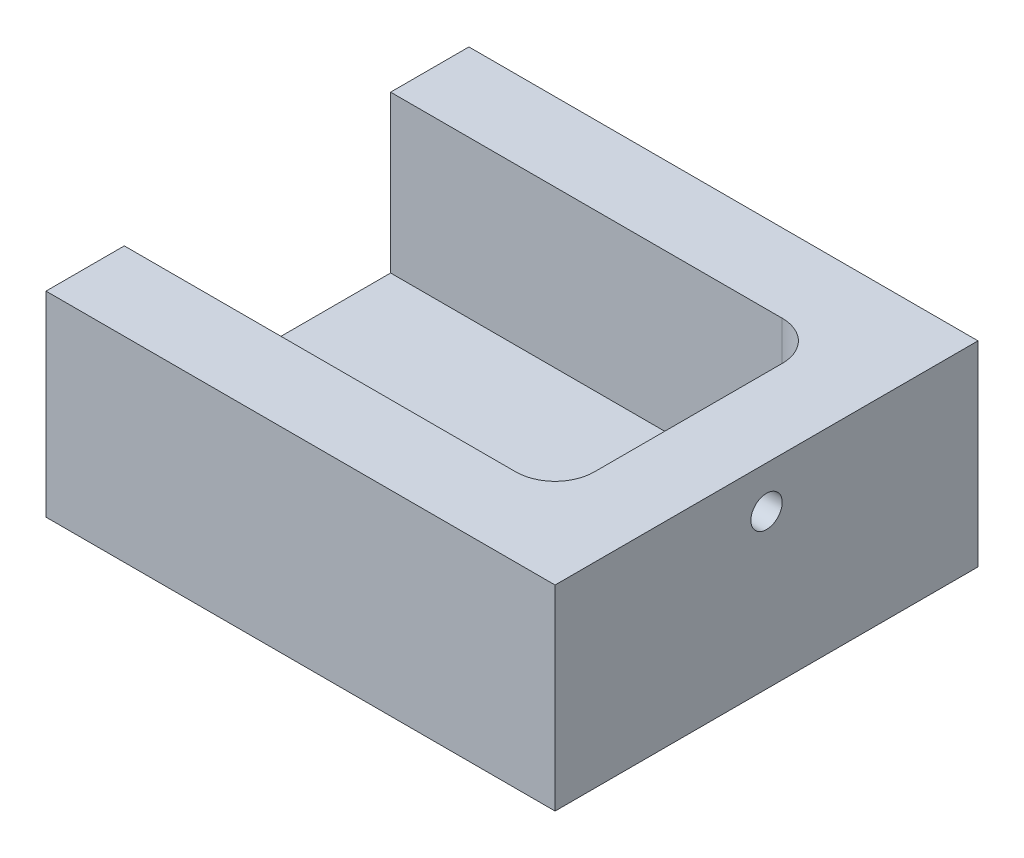
from build123d import *

# Parameters (mm, degrees)
SKETCH1_W           = 65
SKETCH1_H           = 54
BOSS_EXTRUDE1_DEPTH = 25
SKETCH2_W           = 55
SKETCH2_H           = 34
CUT_EXTRUDE1_DEPTH  = 20
SKETCH3_R           = 2
CUT_EXTRUDE2_DEPTH  = 66
FILLET1_R           = 5


with BuildPart() as part:
    # Sketch1 → Boss-Extrude1 (new body)
    with BuildSketch(Plane(origin=(0, 0, 0), x_dir=(1, 0, 0), z_dir=(0, 1, 0))):
        with Locations((32.5, 27)):
            Rectangle(SKETCH1_W, SKETCH1_H)
    extrude(amount=BOSS_EXTRUDE1_DEPTH)

    # Sketch2 → Cut-Extrude1 (cut)
    with BuildSketch(Plane(origin=(0, 25, 0), x_dir=(1, 0, 0), z_dir=(0, 1, 0))):
        with Locations((27.5, 27)):
            Rectangle(SKETCH2_W, SKETCH2_H)
    extrude(amount=-CUT_EXTRUDE1_DEPTH, mode=Mode.SUBTRACT)

    # Sketch3 → Cut-Extrude2 (cut, through all)
    with BuildSketch(Plane(origin=(65, 0, 0), x_dir=(0, 0, -1), z_dir=(1, 0, 0))):
        with Locations((27, 19.64)):
            Circle(SKETCH3_R)
    extrude(amount=-CUT_EXTRUDE2_DEPTH, mode=Mode.SUBTRACT)

    # Fillet1
    fillet1_edges = [part.edges().sort_by_distance(p)[0] for p in [
        (55, 15, -44),
        (55, 15, -10),
    ]]
    fillet(fillet1_edges, radius=FILLET1_R)


solid = part.part
